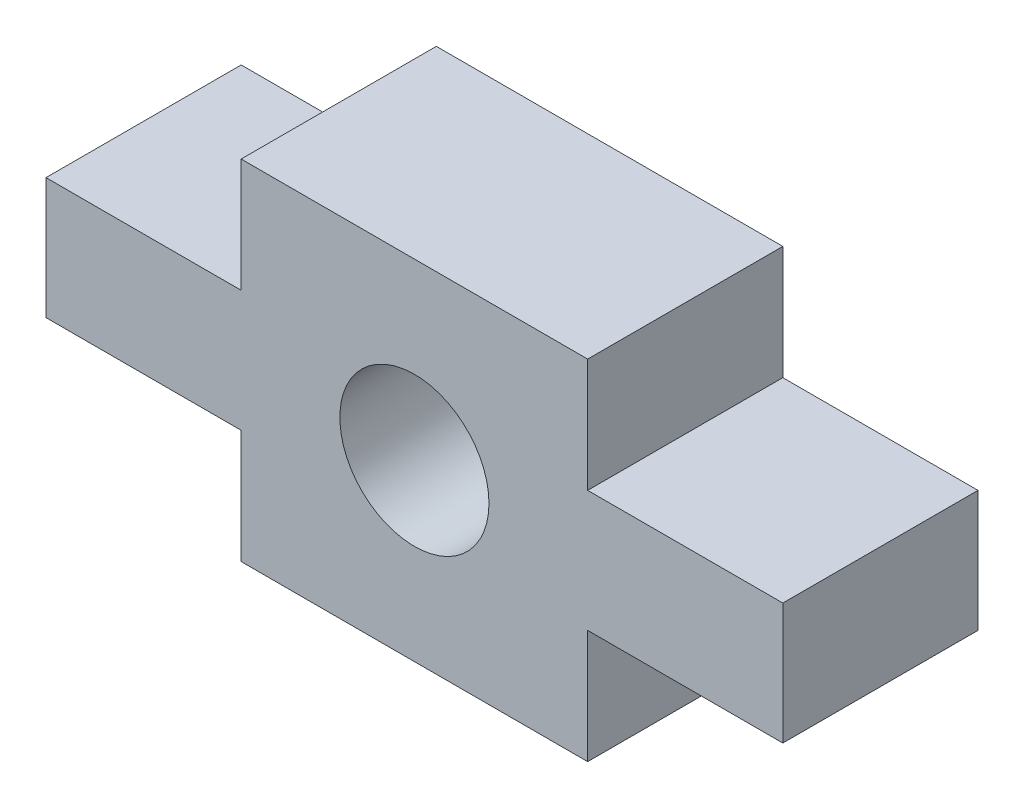
from build123d import *

# Parameters (mm, degrees)
BOSS_EXTRUDE1_DEPTH = 5.15
SKETCH2_R           = 1.9675
CUT_EXTRUDE1_DEPTH  = 6.15


with BuildPart() as part:
    # Sketch1 → Boss-Extrude1 (new body)
    with BuildSketch(Plane.XY):
        Polygon((-0.1, 6.1), (-0.1, 2.9), (5.05, 2.9), (5.05, -0.1), (14.193, -0.1), (14.193, 2.9), (19.343, 2.9), (19.343, 6.1), (14.193, 6.1), (14.193, 9.1), (5.05, 9.1), (5.05, 6.1), align=None)
    extrude(amount=BOSS_EXTRUDE1_DEPTH)

    # Sketch2 → Cut-Extrude1 (cut, through all)
    with BuildSketch(Plane.XY.offset(5.15)):
        with Locations((9.6215, 4.5)):
            Circle(SKETCH2_R)
    extrude(amount=-CUT_EXTRUDE1_DEPTH, mode=Mode.SUBTRACT)


solid = part.part
